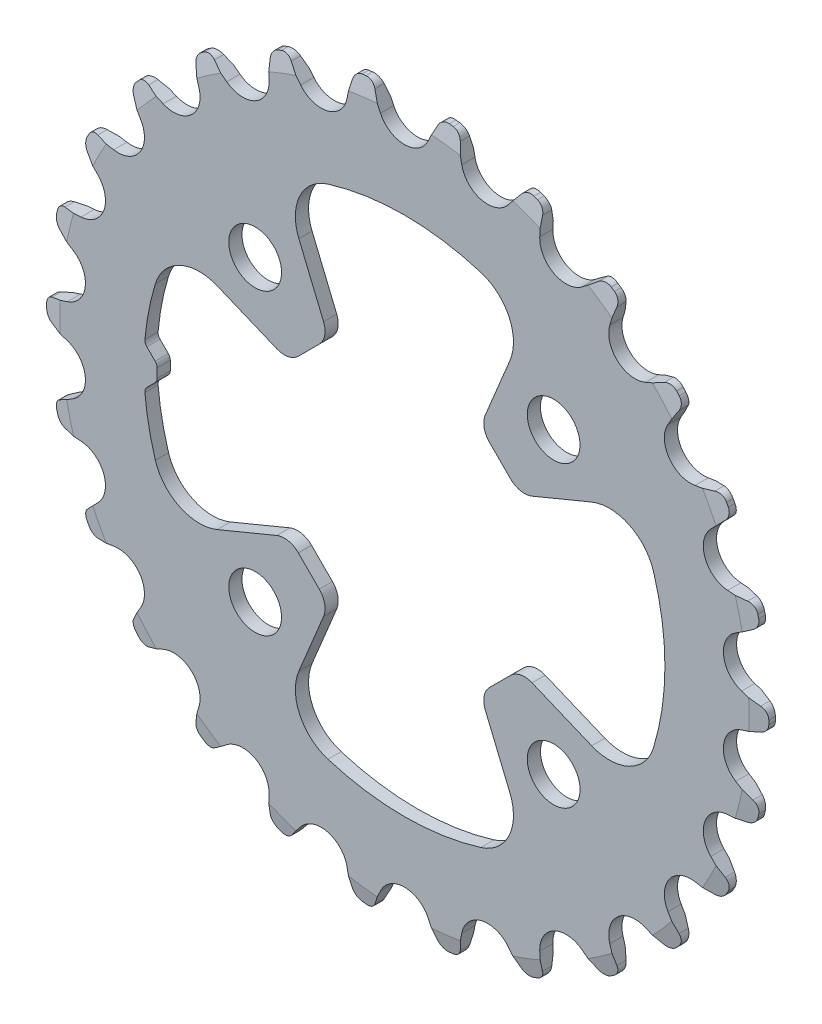
from build123d import *

# Parameters (mm, degrees)
ESQUISSE1_R                  = 54.75
EXTRUSION1_DEPTH             = 1
ENL_V_MAT_EXTRU_1_DEPTH      = 2
R_P_TITION_CIRCULAIRE1_COUNT = 26
ESQUISSE5_R                  = 4
ENL_V_MAT_EXTRU_2_DEPTH      = 2.0000001
ENL_V_MAT_EXTRU_2_DEPTH_BACK = 2.0000001
ENL_V_MAT_EXTRU_3_DEPTH      = 2.0000001
ENL_V_MAT_EXTRU_3_DEPTH_BACK = 2.0000001


with BuildPart() as part:
    # Esquisse1 → Extrusion1 (new body, symmetric)
    with BuildSketch(Plane.XY):
        Circle(ESQUISSE1_R)
    extrude(amount=EXTRUSION1_DEPTH, both=True)

    # Esquisse4 → Enlèvement de matière-Révolution1 (revolve, cut)
    with BuildSketch(Plane(origin=(0, 0, 0), x_dir=(0, 0, -1), z_dir=(1, 0, 0)), mode=Mode.PRIVATE) as enl_vement_de_mati_re_r_volution1_sk:
        Polygon((-1, 54.75), (-0.5, 54.75), (-1, 52.25), align=None)
        Polygon((1, 54.75), (0.5, 54.75), (1, 52.25), align=None)
    revolve(enl_vement_de_mati_re_r_volution1_sk.sketch.rotate(Axis((0, 0, 6.759259259), (0, 0, -1)), 90), axis=Axis((0, 0, 6.759259259), (0, 0, -1)), mode=Mode.SUBTRACT)  # turned: the seam where the file's is

    # Esquisse2 → Enlèv. mat.-Extru.1 (cut, symmetric)
    with BuildSketch(Plane.XY):
        with BuildLine():
            Line((-4.776851114, 53.529183941), (-3.625231148, 51.059526953))
            ThreePointArc((-3.625231148, 51.059526953), (0, 48.75), (3.625231148, 51.059526953))
            Line((3.625231148, 51.059526953), (4.776851114, 53.529183941))
            ThreePointArc((4.776851114, 53.529183941), (5.404720226, 54.204749699), (6.309166677, 54.385263775))
            ThreePointArc((6.309166677, 54.385263775), (0, 54.75), (-6.309166677, 54.385263775))
            ThreePointArc((-6.309166677, 54.385263775), (-5.404720226, 54.204749699), (-4.776851114, 53.529183941))
        make_face()
    enl_v_mat_extru_1 = extrude(amount=ENL_V_MAT_EXTRU_1_DEPTH, both=True, mode=Mode.SUBTRACT)

    # Répétition circulaire1: Enlèv. mat.-Extru.1 ×26 about axis
    r_p_tition_circulaire1_axis = Axis((0, 0, 0), (0, 0, 1))
    for i in range(1, R_P_TITION_CIRCULAIRE1_COUNT):
        add(enl_v_mat_extru_1.rotate(r_p_tition_circulaire1_axis, i * 360 / R_P_TITION_CIRCULAIRE1_COUNT), mode=Mode.SUBTRACT)

    # Esquisse5 → Enlèv. mat.-Extru.2 (cut, two sides)
    with BuildSketch(Plane.XY) as enl_v_mat_extru_2_sk:
        with Locations((-22.627416998, 22.627416998)):
            Circle(ESQUISSE5_R)
        with Locations(Location((22.627416998, 22.627416998, 0), (0, 0, 180))):  # turned: the seam where the file's is
            Circle(ESQUISSE5_R)
        with Locations(Location((-22.627416998, -22.627416998, 0), (0, 0, 180))):  # turned: the seam where the file's is
            Circle(ESQUISSE5_R)
        with Locations((22.627416998, -22.627416998)):
            Circle(ESQUISSE5_R)
    extrude(amount=ENL_V_MAT_EXTRU_2_DEPTH, mode=Mode.SUBTRACT)
    extrude(enl_v_mat_extru_2_sk.sketch, amount=-ENL_V_MAT_EXTRU_2_DEPTH_BACK, mode=Mode.SUBTRACT)

    # Esquisse6 → Enlèv. mat.-Extru.3 (cut, two sides)
    with BuildSketch(Plane.XY) as enl_v_mat_extru_3_sk:
        with BuildLine():
            Line((12.907906132, 16.083471897), (16.083471897, 12.907906132))
            ThreePointArc((16.083471897, 12.907906132), (17.619521274, 12.086870634), (19.352842537, 12.257587878))
            Line((19.352842537, 12.257587878), (28.391261875, 16.00142375))
            ThreePointArc((28.391261875, 16.00142375), (34.052747845, 15.866998591), (37.762055788, 11.587801458))
            ThreePointArc((37.762055788, 11.587801458), (39.5, 0), (37.762055788, -11.587801458))
            ThreePointArc((37.762055788, -11.587801458), (34.052747845, -15.866998591), (28.391261875, -16.00142375))
            Line((28.391261875, -16.00142375), (19.352842537, -12.257587878))
            ThreePointArc((19.352842537, -12.257587878), (17.619521274, -12.086870634), (16.083471897, -12.907906132))
            Line((16.083471897, -12.907906132), (12.907906132, -16.083471897))
            ThreePointArc((12.907906132, -16.083471897), (12.086870634, -17.619521274), (12.257587878, -19.352842537))
            Line((12.257587878, -19.352842537), (16.00142375, -28.391261875))
            ThreePointArc((16.00142375, -28.391261875), (15.866998591, -34.052747845), (11.587801458, -37.762055788))
            ThreePointArc((11.587801458, -37.762055788), (0, -39.5), (-11.587801458, -37.762055788))
            ThreePointArc((-11.587801458, -37.762055788), (-15.866998591, -34.052747845), (-16.00142375, -28.391261875))
            Line((-16.00142375, -28.391261875), (-12.257587878, -19.352842537))
            ThreePointArc((-12.257587878, -19.352842537), (-12.086870634, -17.619521274), (-12.907906132, -16.083471897))
            Line((-12.907906132, -16.083471897), (-16.083471897, -12.907906132))
            ThreePointArc((-16.083471897, -12.907906132), (-17.619521274, -12.086870634), (-19.352842537, -12.257587878))
            Line((-19.352842537, -12.257587878), (-28.391261875, -16.00142375))
            ThreePointArc((-28.391261875, -16.00142375), (-34.052747845, -15.866998591), (-37.762055788, -11.587801458))
            ThreePointArc((-37.762055788, -11.587801458), (-38.767981188, -7.569255882), (-39.347512354, -3.467458947))
            ThreePointArc((-39.347512354, -3.467458947), (-39.291173187, -3.037951262), (-39.058479582, -2.672568395))
            Line((-39.058479582, -2.672568395), (-37.792893219, -1.406982032))
            ThreePointArc((-37.792893219, -1.406982032), (-37.576120467, -1.082558683), (-37.5, -0.699875251))
            Line((-37.5, -0.699875251), (-37.5, 0.699875251))
            ThreePointArc((-37.5, 0.699875251), (-37.576120467, 1.082558683), (-37.792893219, 1.406982032))
            Line((-37.792893219, 1.406982032), (-39.058479582, 2.672568395))
            ThreePointArc((-39.058479582, 2.672568395), (-39.291173187, 3.037951262), (-39.347512354, 3.467458947))
            ThreePointArc((-39.347512354, 3.467458947), (-38.767981188, 7.569255882), (-37.762055788, 11.587801458))
            ThreePointArc((-37.762055788, 11.587801458), (-34.052747845, 15.866998591), (-28.391261875, 16.00142375))
            Line((-28.391261875, 16.00142375), (-19.352842537, 12.257587878))
            ThreePointArc((-19.352842537, 12.257587878), (-17.619521274, 12.086870634), (-16.083471897, 12.907906132))
            Line((-16.083471897, 12.907906132), (-12.907906132, 16.083471897))
            ThreePointArc((-12.907906132, 16.083471897), (-12.086870634, 17.619521274), (-12.257587878, 19.352842537))
            Line((-12.257587878, 19.352842537), (-16.00142375, 28.391261875))
            ThreePointArc((-16.00142375, 28.391261875), (-15.866998591, 34.052747845), (-11.587801458, 37.762055788))
            ThreePointArc((-11.587801458, 37.762055788), (0, 39.5), (11.587801458, 37.762055788))
            ThreePointArc((11.587801458, 37.762055788), (15.866998591, 34.052747845), (16.00142375, 28.391261875))
            Line((16.00142375, 28.391261875), (12.257587878, 19.352842537))
            ThreePointArc((12.257587878, 19.352842537), (12.086870634, 17.619521274), (12.907906132, 16.083471897))
        make_face()
    extrude(amount=ENL_V_MAT_EXTRU_3_DEPTH, mode=Mode.SUBTRACT)
    extrude(enl_v_mat_extru_3_sk.sketch, amount=-ENL_V_MAT_EXTRU_3_DEPTH_BACK, mode=Mode.SUBTRACT)


solid = part.part
